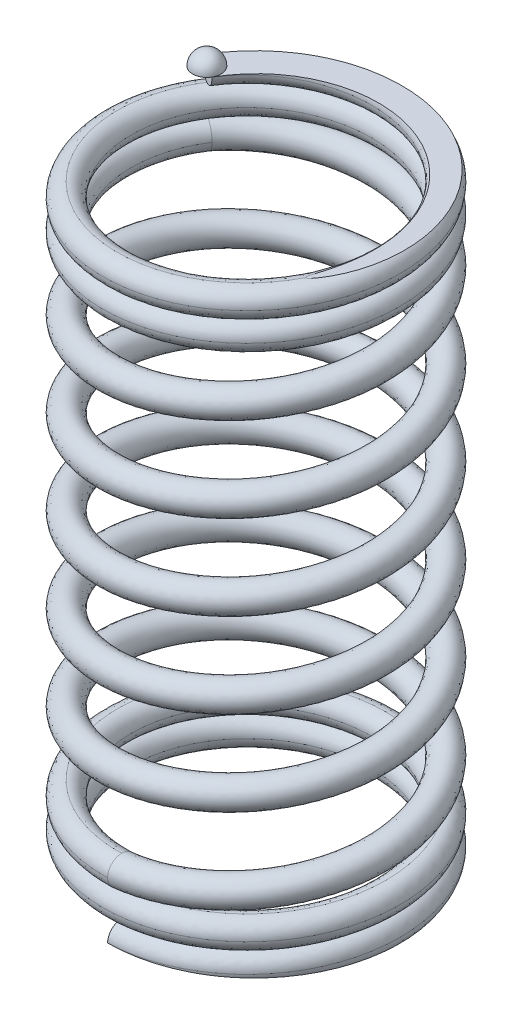
from build123d import *

# Parameters (mm, degrees)
SWEEP5_PITCH       = 1
SWEEP5_HEIGHT      = 2
SWEEP5_RADIUS      = 4.75
SKETCH7_R          = 0.5
SWEEP6_PITCH       = 3
SWEEP6_HEIGHT      = 17
SWEEP6_RADIUS      = 4.75
SKETCH15_R         = 0.5
SKETCH18_W         = 13.014589774
SKETCH18_H         = 2.714870451
CUT_EXTRUDE1_DEPTH = 7.5
SWEEP7_PITCH       = 1
SWEEP7_HEIGHT      = 2
SWEEP7_RADIUS      = 4.75
SWEEP7_START_ANGLE = -120
SKETCH27_R         = 0.5
CUT_EXTRUDE2_DEPTH = 7.5


with BuildPart() as part:
    # Sweep5: sweep along a helix
    with BuildLine() as sweep5_path:
        Helix(SWEEP5_PITCH, SWEEP5_HEIGHT, SWEEP5_RADIUS, center=(0, 0, 0), direction=(0, 1, 0))
    # Sketch7 → Sweep5 (sweep)
    with BuildSketch(Plane(origin=(0, 0, 0), x_dir=(0, 0, -1), z_dir=(1, 0, 0))):
        with Locations((-4.75, 0)):
            Circle(SKETCH7_R)
    sweep(path=sweep5_path.line, is_frenet=True)

    # Sweep6: sweep along a helix
    with BuildLine() as sweep6_path:
        Helix(SWEEP6_PITCH, SWEEP6_HEIGHT, SWEEP6_RADIUS, center=(0, 2, 0), direction=(0, 1, 0))
    # Sketch15 → Sweep6 (sweep)
    with BuildSketch(Plane(origin=(0, 0, 0), x_dir=(0, 0, -1), z_dir=(1, 0, 0))):
        with Locations((-4.75, 2)):
            Circle(SKETCH15_R)
    sweep(path=sweep6_path.line, is_frenet=True)

    # Sketch18 → Cut-Extrude1 (cut, symmetric)
    with BuildSketch(Plane.ZY):
        with Locations((0.483000348, -1.357435226)):
            Rectangle(SKETCH18_W, SKETCH18_H)
    extrude(amount=CUT_EXTRUDE1_DEPTH, both=True, mode=Mode.SUBTRACT)

    # Sweep7: sweep along a helix
    with BuildLine() as sweep7_path:
        add(Helix(SWEEP7_PITCH, SWEEP7_HEIGHT, SWEEP7_RADIUS, center=(0, 19, 0), direction=(0, 1, 0), mode=Mode.PRIVATE).rotate(Axis((0, 19, 0), (0, 1, 0)), SWEEP7_START_ANGLE))
    # Sketch27 → Sweep7 (sweep)
    with BuildSketch(Plane(origin=(0, 0, 0), x_dir=(0.866025404, 0, 0.5), z_dir=(-0.5, 0, 0.866025404))):
        with Locations((-4.75, 19.000739182)):
            Circle(SKETCH27_R)
    sweep(path=sweep7_path.line, is_frenet=True)

    # Sketch28 → Cut-Extrude2 (cut, symmetric)
    with BuildSketch(Plane(origin=(0, 0, 0), x_dir=(0.866025404, 0, 0.5), z_dir=(-0.5, 0, 0.866025404))):
        Polygon((-5.353171486, 21.000739182), (-3.995912541, 21.000739182), (7.309612645, 21.000739182), (7.309612645, 23.840590572), (-5.353171486, 23.840590572), align=None)
    extrude(amount=CUT_EXTRUDE2_DEPTH, both=True, mode=Mode.SUBTRACT)

    # Sketch29 → Revolve1 (revolve)
    with BuildSketch(Plane(origin=(0, 0, 0), x_dir=(0.866025404, 0, 0.5), z_dir=(-0.5, 0, 0.866025404))):
        with BuildLine():
            Line((-5.25, 21.000739182), (-4.75, 21.000739182))
            Line((-4.75, 21.000739182), (-4.75, 21.500739182))
            ThreePointArc((-4.75, 21.500739182), (-5.103553391, 21.354292572), (-5.25, 21.000739182))
        make_face()
    revolve(axis=Axis((-4.113620668, 21.75571771, -2.375), (0, -1, 0)))


solid = part.part
